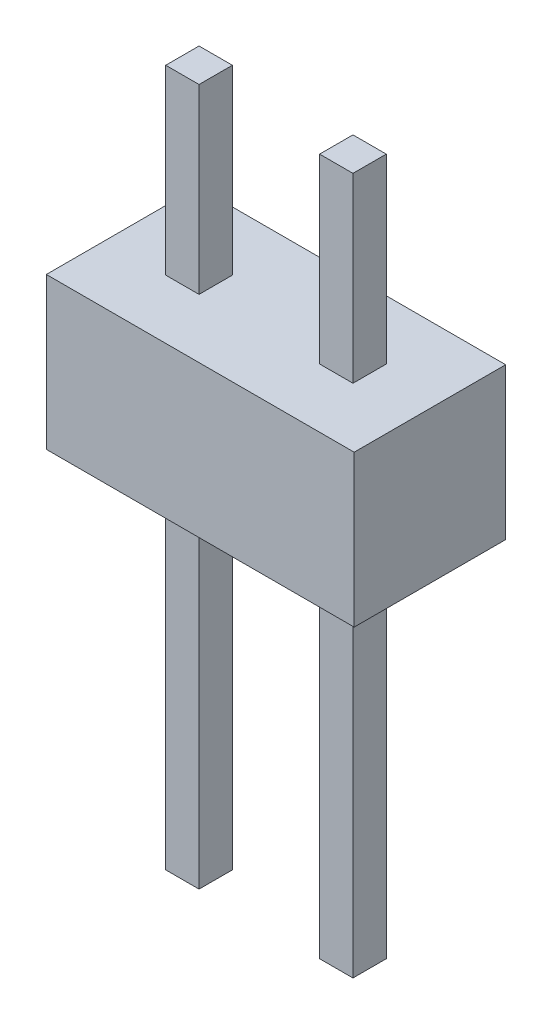
from build123d import *

# Parameters (mm, degrees)
SKETCH1_W             = 5.08
SKETCH1_H             = 2.5
BOSS_EXTRUDE1_DEPTH   = 1.25
SKETCH2_W             = 0.55
SKETCH2_H             = 0.55
BOSS_EXTRUDE2_DEPTH   = 6
BOSS_EXTRUDE2_2_DEPTH = 6
SKETCH2_2_W           = 0.55
SKETCH2_2_H           = 0.55
BOSS_EXTRUDE3_DEPTH   = 5.5
BOSS_EXTRUDE3_2_DEPTH = 5.5


with BuildPart() as part:
    # Sketch1 → Boss-Extrude1 (new body, symmetric)
    with BuildSketch(Plane.XY):
        with Locations((2.54, 1.25)):
            Rectangle(SKETCH1_W, SKETCH1_H)
    extrude(amount=BOSS_EXTRUDE1_DEPTH, both=True)


with BuildPart() as body_2:
    # Sketch2 → Boss-Extrude2 (new body)
    with BuildSketch(Plane.XZ):
        with Locations((3.81, 0)):
            Rectangle(SKETCH2_W, SKETCH2_H)
    extrude(amount=BOSS_EXTRUDE2_DEPTH)


with BuildPart() as body_3:
    # Sketch2 → Boss-Extrude2 2 (new body)
    with BuildSketch(Plane.XZ):
        with Locations((1.27, 0)):
            Rectangle(SKETCH2_W, SKETCH2_H)
    extrude(amount=BOSS_EXTRUDE2_2_DEPTH)


with BuildPart() as body_4:
    # Sketch2_2 → Boss-Extrude3 (new body)
    with BuildSketch(Plane.XZ):
        with Locations((3.81, 0)):
            Rectangle(SKETCH2_2_W, SKETCH2_2_H)
    extrude(amount=-BOSS_EXTRUDE3_DEPTH)


with BuildPart() as body_5:
    # Sketch2_2 → Boss-Extrude3 2 (new body)
    with BuildSketch(Plane.XZ):
        with Locations((1.27, 0)):
            Rectangle(SKETCH2_2_W, SKETCH2_2_H)
    extrude(amount=-BOSS_EXTRUDE3_2_DEPTH)


solid = Compound([part.part, body_2.part, body_3.part, body_4.part, body_5.part])
